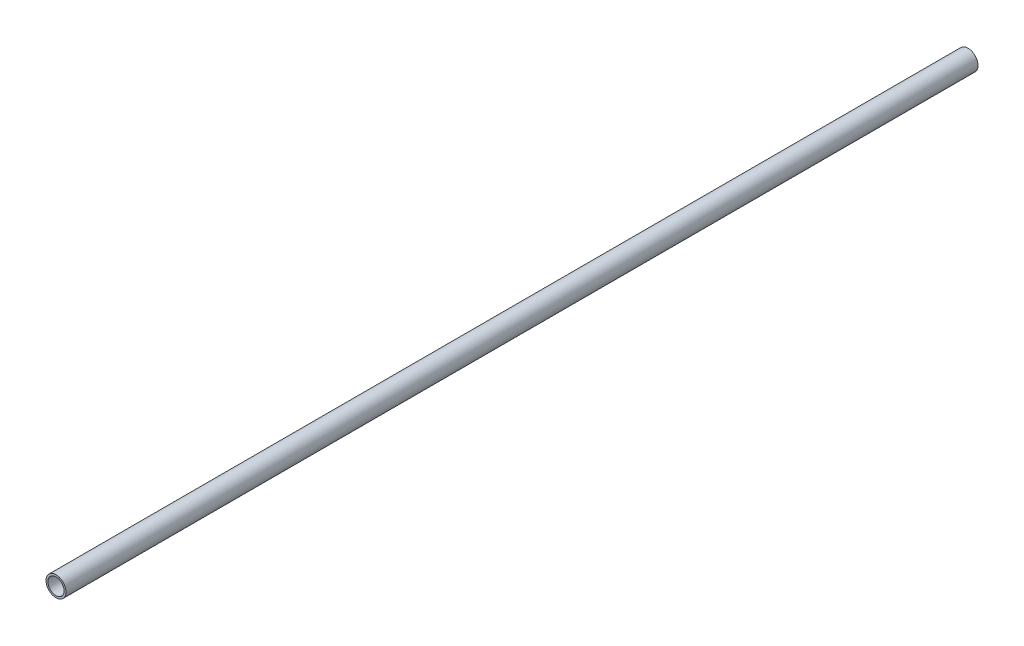
from build123d import *

# Parameters (mm, degrees)
EXTRUDE_START   = -4
SKETCH_1_R      = 10.65
SKETCH_1_R_2    = 8.65
EXTRUDE_1_DEPTH = 485.6


with BuildPart() as part:
    # Эскиз1 → Бобышка-Вытянуть1 (new body)
    with BuildSketch(Plane.XY.offset(EXTRUDE_START)):
        with Locations((208.749166476, -10.65)):
            Circle(SKETCH_1_R)
        with Locations((208.749166476, -10.65)):
            Circle(SKETCH_1_R_2, mode=Mode.SUBTRACT)
    extrude_1 = extrude(amount=-EXTRUDE_1_DEPTH)

    # Зеркальное отражение1: Бобышка-Вытянуть1 across plane
    add(extrude_1.mirror(Plane(origin=(-190.563941192, 31.462012182, -489.6), x_dir=(1, 0, 0), z_dir=(0, 0, 1))))


solid = part.part
